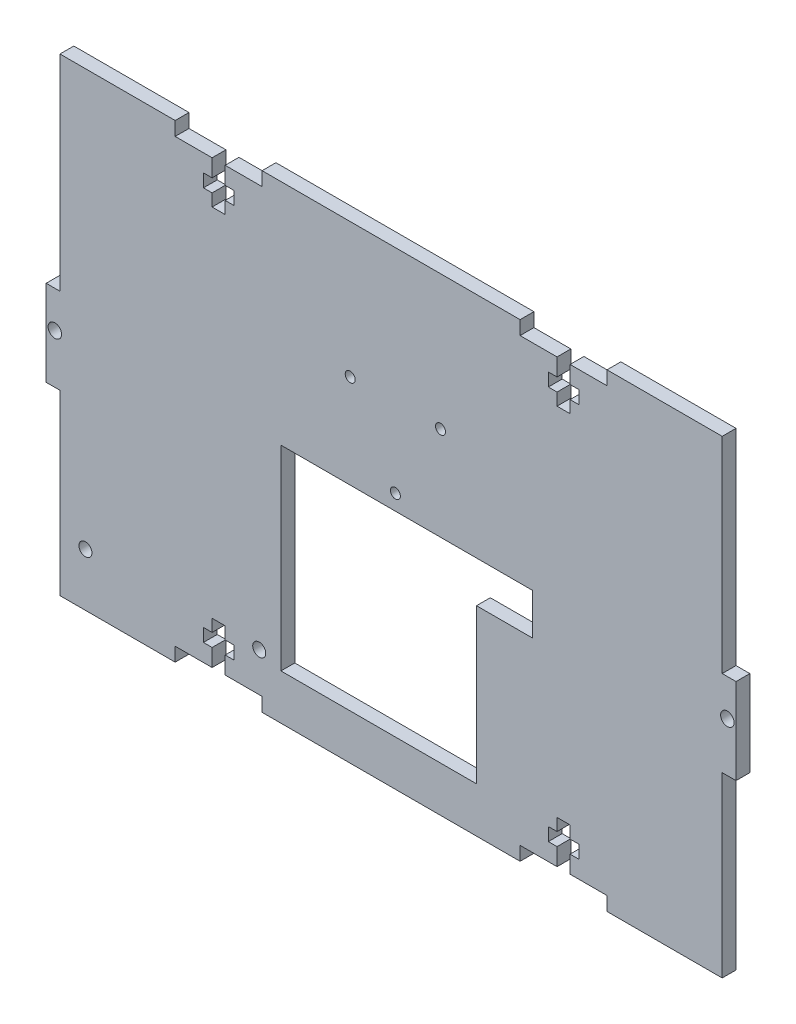
from build123d import *

# Parameters (mm, degrees)
SKETCH2_W                = 158.76
SKETCH2_H                = 107.96
BOSS_EXTRUDE2_DEPTH      = 3.18
CUT_EXTRUDE1_START       = -4.18
CUT_EXTRUDE1_DEPTH       = 5.18
CUT_EXTRUDE2_START       = -4.18
SKETCH4_3_W              = 20
SKETCH4_3_H              = 3.18
CUT_EXTRUDE2_DEPTH       = 5.18
CUT_EXTRUDE3_START       = -4.18
SKETCH7_W                = 3.18
SKETCH7_H                = 47.285
CUT_EXTRUDE3_DEPTH       = 5.18
MIRROR8_START            = -4.18
MIRROR8_COPY_1_DEPTH     = 5.18
MIRROR8_COPY_2_SKETCH_W  = 20
MIRROR8_COPY_2_SKETCH_H  = 3.18
MIRROR8_COPY_2_DEPTH     = 5.18
CUT_EXTRUDE5_START       = -4.18
SKETCH9_W                = 3.18
SKETCH9_H                = 40.925
CUT_EXTRUDE5_DEPTH       = 5.18
CUT_EXTRUDE6_START       = -4.18
SKETCH10_R               = 1.55
CUT_EXTRUDE6_DEPTH       = 5.18
SKETCH11_W               = 45
SKETCH11_H               = 45
CUT_EXTRUDE7_DEPTH       = 1
CUT_EXTRUDE7_DEPTH_BACK  = 4.18
SKETCH6_W                = 55
SKETCH6_H                = 9.5
CUT_EXTRUDE8_DEPTH       = 1
CUT_EXTRUDE8_DEPTH_BACK  = 4.18
SKETCH14_R               = 1.149787343
SKETCH14_R_2             = 1.15
CUT_EXTRUDE9_DEPTH       = 1
CUT_EXTRUDE9_DEPTH_BACK  = 4.18
SKETCH15_R               = 1.5
CUT_EXTRUDE10_DEPTH      = 1
CUT_EXTRUDE10_DEPTH_BACK = 4.18


with BuildPart() as part:
    # Sketch2 → Boss-Extrude2 (new body)
    with BuildSketch(Plane.XY):
        Rectangle(SKETCH2_W, SKETCH2_H)
    extrude(amount=BOSS_EXTRUDE2_DEPTH)

    # Sketch4 → Cut-Extrude1 (cut)
    with BuildSketch(Plane.XY.offset(3.18).offset(CUT_EXTRUDE1_START)):
        Polygon((41.19, 46.8), (43.19, 46.8), (43.19, 43.8), (41.19, 43.8), (41.19, 40.98), (38.19, 40.98), (38.19, 43.8), (36.19, 43.8), (36.19, 46.8), (38.19, 46.8), (38.19, 50.8), (41.19, 50.8), align=None)
    cut_extrude1 = extrude(amount=CUT_EXTRUDE1_DEPTH, mode=Mode.SUBTRACT)

    # Sketch4_3 → Cut-Extrude2 (cut)
    with BuildSketch(Plane.XY.offset(3.18).offset(CUT_EXTRUDE2_START)):
        Polygon((41.19, 46.8), (43.19, 46.8), (43.19, 43.8), (41.19, 43.8), (41.19, 40.98), (38.19, 40.98), (38.19, 43.8), (36.19, 43.8), (36.19, 46.8), (38.19, 46.8), (38.19, 50.8), (41.19, 50.8), align=None)
        with Locations((39.69, 52.39)):
            Rectangle(SKETCH4_3_W, SKETCH4_3_H)
    cut_extrude2 = extrude(amount=CUT_EXTRUDE2_DEPTH, mode=Mode.SUBTRACT)

    # Mirror1: Cut-Extrude1, Cut-Extrude2 across plane
    add(cut_extrude1.mirror(Plane(origin=(0, 0, 0), x_dir=(0, 0, 1), z_dir=(1, 0, 0))), mode=Mode.SUBTRACT)
    add(cut_extrude2.mirror(Plane(origin=(0, 0, 0), x_dir=(0, 0, 1), z_dir=(1, 0, 0))), mode=Mode.SUBTRACT)

    # Sketch7 → Cut-Extrude3 (cut)
    with BuildSketch(Plane.XY.offset(3.18).offset(CUT_EXTRUDE3_START)):
        with Locations((-77.79, 30.3375)):
            Rectangle(SKETCH7_W, SKETCH7_H)
    cut_extrude3 = extrude(amount=CUT_EXTRUDE3_DEPTH, mode=Mode.SUBTRACT)

    # Mirror8: Cut-Extrude1, Cut-Extrude2 across plane
    add(cut_extrude1.mirror(Plane.ZX), mode=Mode.SUBTRACT)
    add(cut_extrude2.mirror(Plane.ZX), mode=Mode.SUBTRACT)

    # Mirror8 copy 1 sketch → Mirror8 copy 1 (cut)
    with BuildSketch(Plane(origin=(0, 0, 3.18), x_dir=(-1, 0, 0), z_dir=(0, 0, 1)).offset(MIRROR8_START)):
        Polygon((41.19, 46.8), (43.19, 46.8), (43.19, 43.8), (41.19, 43.8), (41.19, 40.98), (38.19, 40.98), (38.19, 43.8), (36.19, 43.8), (36.19, 46.8), (38.19, 46.8), (38.19, 50.8), (41.19, 50.8), align=None)
    extrude(amount=MIRROR8_COPY_1_DEPTH, mode=Mode.SUBTRACT)

    # Mirror8 copy 2 sketch → Mirror8 copy 2 (cut)
    with BuildSketch(Plane(origin=(0, 0, 3.18), x_dir=(-1, 0, 0), z_dir=(0, 0, 1)).offset(MIRROR8_START)):
        Polygon((41.19, 46.8), (43.19, 46.8), (43.19, 43.8), (41.19, 43.8), (41.19, 40.98), (38.19, 40.98), (38.19, 43.8), (36.19, 43.8), (36.19, 46.8), (38.19, 46.8), (38.19, 50.8), (41.19, 50.8), align=None)
        with Locations((39.69, 52.39)):
            Rectangle(MIRROR8_COPY_2_SKETCH_W, MIRROR8_COPY_2_SKETCH_H)
    extrude(amount=MIRROR8_COPY_2_DEPTH, mode=Mode.SUBTRACT)

    # Mirror10: Cut-Extrude3 across plane
    add(cut_extrude3.mirror(Plane(origin=(0, 0, 0), x_dir=(0, 0, 1), z_dir=(1, 0, 0))), mode=Mode.SUBTRACT)

    # Sketch9 → Cut-Extrude5 (cut)
    with BuildSketch(Plane.XY.offset(3.18).offset(CUT_EXTRUDE5_START)):
        with Locations((-77.79, -33.5175)):
            Rectangle(SKETCH9_W, SKETCH9_H)
    cut_extrude5 = extrude(amount=CUT_EXTRUDE5_DEPTH, mode=Mode.SUBTRACT)

    # Mirror11: Cut-Extrude5 across plane
    add(cut_extrude5.mirror(Plane(origin=(0, 0, 0), x_dir=(0, 0, 1), z_dir=(1, 0, 0))), mode=Mode.SUBTRACT)

    # Sketch10 → Cut-Extrude6 (cut)
    with BuildSketch(Plane.XY.offset(3.18).offset(CUT_EXTRUDE6_START)):
        with Locations((-77.38, -1.733294162)):
            Circle(SKETCH10_R)
    cut_extrude6 = extrude(amount=CUT_EXTRUDE6_DEPTH, mode=Mode.SUBTRACT)

    # Mirror12: Cut-Extrude6 across plane
    add(cut_extrude6.mirror(Plane(origin=(0, 0, 0), x_dir=(0, 0, 1), z_dir=(1, 0, 0))), mode=Mode.SUBTRACT)

    # Sketch11 → Cut-Extrude7 (cut, two sides)
    with BuildSketch(Plane(origin=(0, 0, 0), x_dir=(-1, 0, 0), z_dir=(0, 0, -1))) as cut_extrude7_sk:
        with Locations((2.846591626, -21.053294162)):
            Rectangle(SKETCH11_W, SKETCH11_H)
    extrude(amount=CUT_EXTRUDE7_DEPTH, mode=Mode.SUBTRACT)
    extrude(cut_extrude7_sk.sketch, amount=-CUT_EXTRUDE7_DEPTH_BACK, mode=Mode.SUBTRACT)

    # Sketch6 → Cut-Extrude8 (cut, two sides)
    with BuildSketch(Plane.XY.offset(3.18)) as cut_extrude8_sk:
        with Locations((5, -3.303294162)):
            Rectangle(SKETCH6_W, SKETCH6_H)
    extrude(amount=CUT_EXTRUDE8_DEPTH, mode=Mode.SUBTRACT)
    extrude(cut_extrude8_sk.sketch, amount=-CUT_EXTRUDE8_DEPTH_BACK, mode=Mode.SUBTRACT)

    # Sketch14 → Cut-Extrude9 (cut, two sides)
    with BuildSketch(Plane(origin=(0, 0, 0), x_dir=(-1, 0, 0), z_dir=(0, 0, -1))) as cut_extrude9_sk:
        with Locations((-0.986741707, 5.024655272)):
            Circle(SKETCH14_R)
        with Locations((-11.379046552, 23.021177565)):
            Circle(SKETCH14_R_2)
        with Locations((9.405563139, 23.021177565)):
            Circle(SKETCH14_R_2)
    extrude(amount=CUT_EXTRUDE9_DEPTH, mode=Mode.SUBTRACT)
    extrude(cut_extrude9_sk.sketch, amount=-CUT_EXTRUDE9_DEPTH_BACK, mode=Mode.SUBTRACT)

    # Sketch15 → Cut-Extrude10 (cut, two sides)
    with BuildSketch(Plane(origin=(0, 0, 0), x_dir=(-1, 0, 0), z_dir=(0, 0, -1))) as cut_extrude10_sk:
        with Locations((30.346591626, -41.8)):
            Circle(SKETCH15_R)
        with Locations((70.346591626, -41.8)):
            Circle(SKETCH15_R)
    extrude(amount=CUT_EXTRUDE10_DEPTH, mode=Mode.SUBTRACT)
    extrude(cut_extrude10_sk.sketch, amount=-CUT_EXTRUDE10_DEPTH_BACK, mode=Mode.SUBTRACT)


solid = part.part
